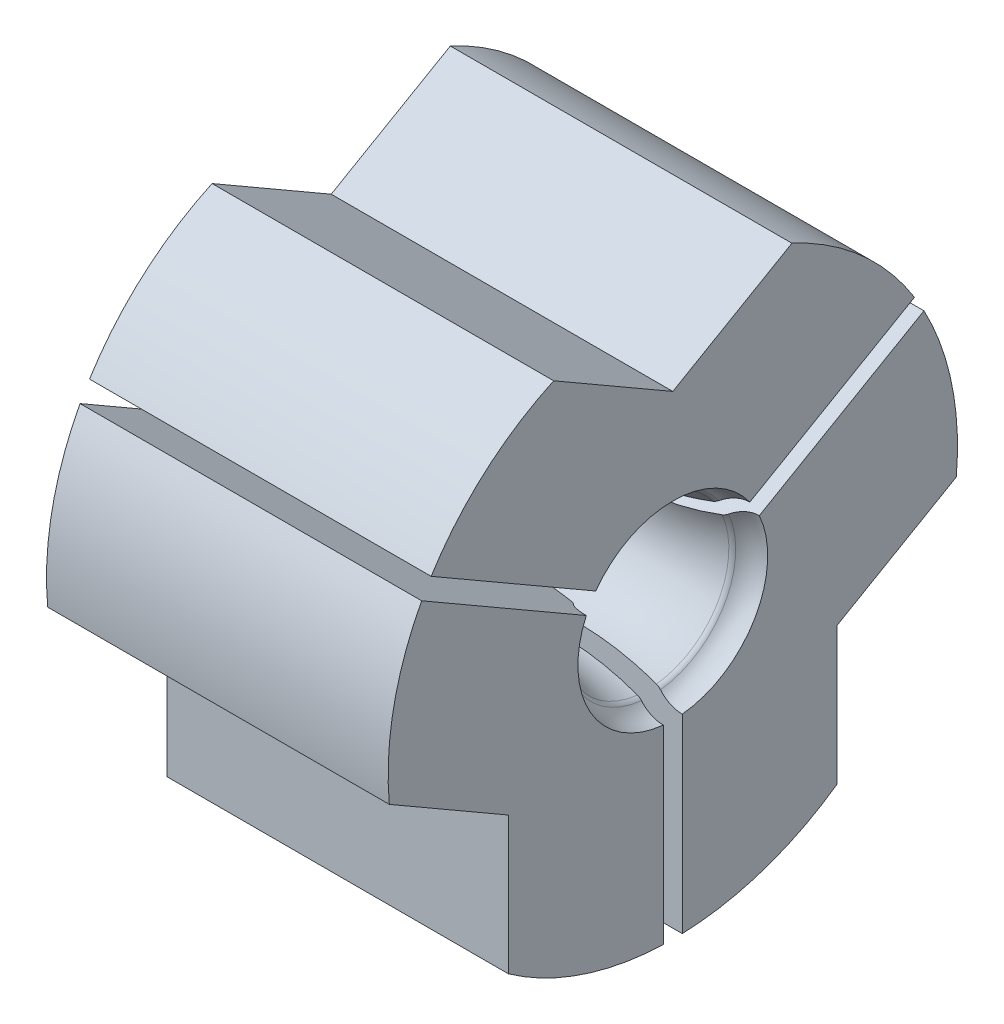
from build123d import *

# Parameters (mm, degrees)
BOSS_EXTRUDE1_START = 2
BOSS_EXTRUDE1_DEPTH = 18
CIRPATTERN2_COUNT   = 3


with BuildPart() as part:
    # Sketch1 → Revolve1 (revolve)
    with BuildSketch(Plane.XY):
        with BuildLine():
            Line((0, 0), (0, -7.5))
            Line((0, -7.5), (3, -7.5))
            Line((3, -7.5), (3, -7.285575219))
            ThreePointArc((3, -7.285575219), (3.328989928, -6.815728909), (3.883022222, -6.964181415))
            ThreePointArc((3.883022222, -6.964181415), (4.963095178, -7.498412449), (6.087690859, -7.065694363))
            ThreePointArc((6.087690859, -7.065694363), (11.964286127, -3.869293654), (18.639015656, -4.315763304))
            ThreePointArc((18.639015656, -4.315763304), (18.754740508, -4.376028032), (18.850933335, -4.464181415))
            ThreePointArc((18.850933335, -4.464181415), (20.017249746, -4.999900812), (21.170937125, -4.4375))
            ThreePointArc((21.170937125, -4.4375), (21.555499584, -4.250033063), (21.944271721, -4.428606195))
            ThreePointArc((21.944271721, -4.428606195), (23.455019356, -5.587843627), (25.31413661, -6))
            Line((25.31413661, -6), (28, -6))
            Line((28, -6), (28, 0))
            Line((28, 0), (0, 0))
        make_face()
    revolve(axis=Axis((0, 0, 0), (-1, 0, 0)))


with BuildPart() as body_2:
    # Sketch3 → Boss-Extrude1 (new body)
    with BuildSketch(Plane(origin=(0, 0, 0), x_dir=(0, 0, -1), z_dir=(1, 0, 0)).offset(BOSS_EXTRUDE1_START)):
        with BuildLine():
            Line((12.733162173, 7.928844877), (0, 0.577350269))
            Line((0, 0.577350269), (-12.733162173, 7.928844877))
            ThreePointArc((-12.733162173, 7.928844877), (-9.922171464, 11.249467251), (-6.276474699, 13.623724357))
            Line((-6.276474699, 13.623724357), (0, 10))
            Line((0, 10), (6.276474699, 13.623724357))
            ThreePointArc((6.276474699, 13.623724357), (9.922171464, 11.249467251), (12.733162173, 7.928844877))
        make_face()
    extrude(amount=BOSS_EXTRUDE1_DEPTH)

    # Combine1: cut part
    add(part.part, mode=Mode.SUBTRACT)


with BuildPart() as cirpattern2_1:
    # CirPattern2: pattern copy
    add(body_2.part.rotate(Axis((0, 0, 0), (1, 0, 0)), 1 * 360 / CIRPATTERN2_COUNT))


with BuildPart() as cirpattern2_2:
    # CirPattern2: pattern copy
    add(body_2.part.rotate(Axis((0, 0, 0), (1, 0, 0)), 2 * 360 / CIRPATTERN2_COUNT))


solid = Compound([body_2.part, cirpattern2_1.part, cirpattern2_2.part])
